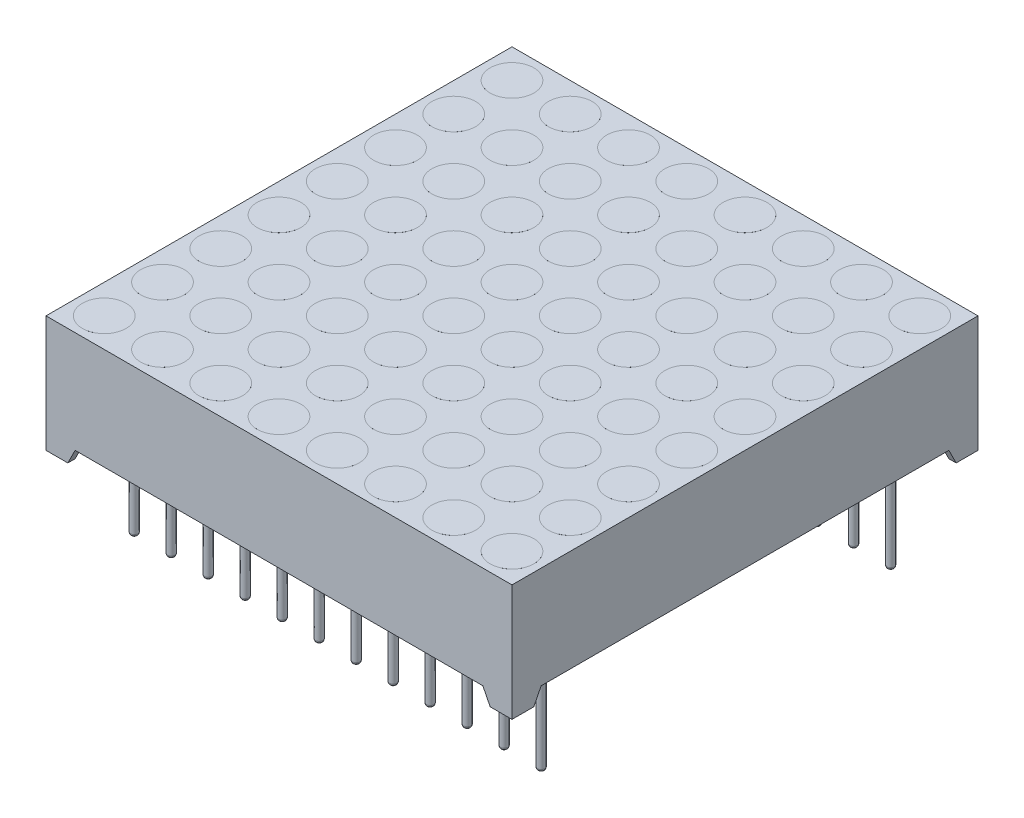
from build123d import *

# Parameters (mm, degrees)
SKETCH1_W              = 32
SKETCH1_H              = 32
BOSS_EXTRUDE1_DEPTH    = 8
SHELL1_T               = -0.5
CUT_EXTRUDE1_DEPTH     = 33
CIRPATTERN1_COUNT      = 2
CIRPATTERN1_ANGLE      = 90
SKETCH3_R              = 1.5
BOSS_EXTRUDE2_DEPTH    = 0.001
LPATTERN1_COUNT        = 8
LPATTERN1_PITCH        = 4
LPATTERN1_COUNT_DIR2   = 8
LPATTERN1_PITCH_DIR2   = 4
SKETCH4_R              = 0.25
BOSS_EXTRUDE3_DEPTH    = 13.5
FILLET1_R              = 0.2
LPATTERN2_COUNT        = 12
LPATTERN2_PITCH        = 2.54
LPATTERN2_COUNT_DIR2   = 2
LPATTERN2_PITCH_DIR2   = 24
FILLET1_OF_LPATTERN2_R = 0.2
SKETCH5_W              = 31
SKETCH5_H              = 31
BOSS_EXTRUDE4_DEPTH    = 5
FILLET2_R              = 1


with BuildPart() as part:
    # Sketch1 → Boss-Extrude1 (new body)
    with BuildSketch(Plane(origin=(0, 0, 0), x_dir=(1, 0, 0), z_dir=(0, 1, 0))):
        Rectangle(SKETCH1_W, SKETCH1_H)
    extrude(amount=BOSS_EXTRUDE1_DEPTH)

    # Shell1
    shell1_openings = [part.faces().sort_by_distance(p)[0] for p in [
        (0, 0, 0),
    ]]
    offset(amount=SHELL1_T, openings=shell1_openings, kind=Kind.INTERSECTION)

    # Sketch2 → Cut-Extrude1 (cut, through all)
    with BuildSketch(Plane.XY.offset(16)):
        Polygon((-14.5, 0), (-14, 1), (14, 1), (14.5, 0), align=None)
    cut_extrude1 = extrude(amount=-CUT_EXTRUDE1_DEPTH, mode=Mode.SUBTRACT)

    # CirPattern1: Cut-Extrude1 ×2 about axis
    cirpattern1_axis = Axis((0, 8.4, 0), (0, -1, 0))
    for i in range(1, CIRPATTERN1_COUNT):
        add(cut_extrude1.rotate(cirpattern1_axis, i * CIRPATTERN1_ANGLE / (CIRPATTERN1_COUNT - 1)), mode=Mode.SUBTRACT)

    # Sketch3 → Boss-Extrude2 (add)
    with BuildSketch(Plane(origin=(0, 8, 0), x_dir=(-1, 0, 0), z_dir=(0, 1, 0))):
        with Locations((-14, 14)):
            Circle(SKETCH3_R)
    boss_extrude2 = extrude(amount=BOSS_EXTRUDE2_DEPTH)

    # LPattern1: Boss-Extrude2 8 × 8
    with Locations(*[(-i * LPATTERN1_PITCH, 0, -j * LPATTERN1_PITCH_DIR2) for i in range(LPATTERN1_COUNT) for j in range(LPATTERN1_COUNT_DIR2) if (i, j) != (0, 0)]):
        add(boss_extrude2)

    # Sketch4 → Boss-Extrude3 (add)
    with BuildSketch(Plane.XZ.offset(-7.5)):
        with Locations((14, -12)):
            Circle(SKETCH4_R)
    boss_extrude3 = extrude(amount=BOSS_EXTRUDE3_DEPTH)

    # Fillet1
    fillet1_edges = [part.edges().sort_by_distance(p)[0] for p in [
        (13.75, -6, -12),
    ]]
    fillet(fillet1_edges, radius=FILLET1_R)

    # LPattern2: Boss-Extrude3 12 × 2
    with Locations(*[(-i * LPATTERN2_PITCH, 0, j * LPATTERN2_PITCH_DIR2) for i in range(LPATTERN2_COUNT) for j in range(LPATTERN2_COUNT_DIR2) if (i, j) != (0, 0)]):
        add(boss_extrude3)

    # Fillet1 of LPattern2
    fillet1_of_lpattern2_edges = [part.edges().sort_by_distance(p)[0] for p in [
        (13.75, -6, 12),
        (11.21, -6, -12),
        (11.21, -6, 12),
        (8.67, -6, -12),
        (8.67, -6, 12),
        (6.13, -6, -12),
        (6.13, -6, 12),
        (3.59, -6, -12),
        (3.59, -6, 12),
        (1.05, -6, -12),
        (1.05, -6, 12),
        (-1.49, -6, -12),
        (-1.49, -6, 12),
        (-4.03, -6, -12),
        (-4.03, -6, 12),
        (-6.57, -6, -12),
        (-6.57, -6, 12),
        (-9.11, -6, -12),
        (-9.11, -6, 12),
        (-11.65, -6, -12),
        (-11.65, -6, 12),
        (-14.19, -6, -12),
        (-14.19, -6, 12),
    ]]
    fillet(fillet1_of_lpattern2_edges, radius=FILLET1_OF_LPATTERN2_R)

    # Sketch5 → Boss-Extrude4 (add)
    with BuildSketch(Plane.XZ.offset(-7.5)):
        Rectangle(SKETCH5_W, SKETCH5_H)
    extrude(amount=BOSS_EXTRUDE4_DEPTH)

    # Fillet2
    fillet2_edges = [part.edges().sort_by_distance(p)[0] for p in [
        (0, 2.5, 15.5),
        (-15.5, 2.5, 0),
        (0, 2.5, -15.5),
        (15.5, 2.5, 0),
    ]]
    fillet(fillet2_edges, radius=FILLET2_R)


solid = part.part
